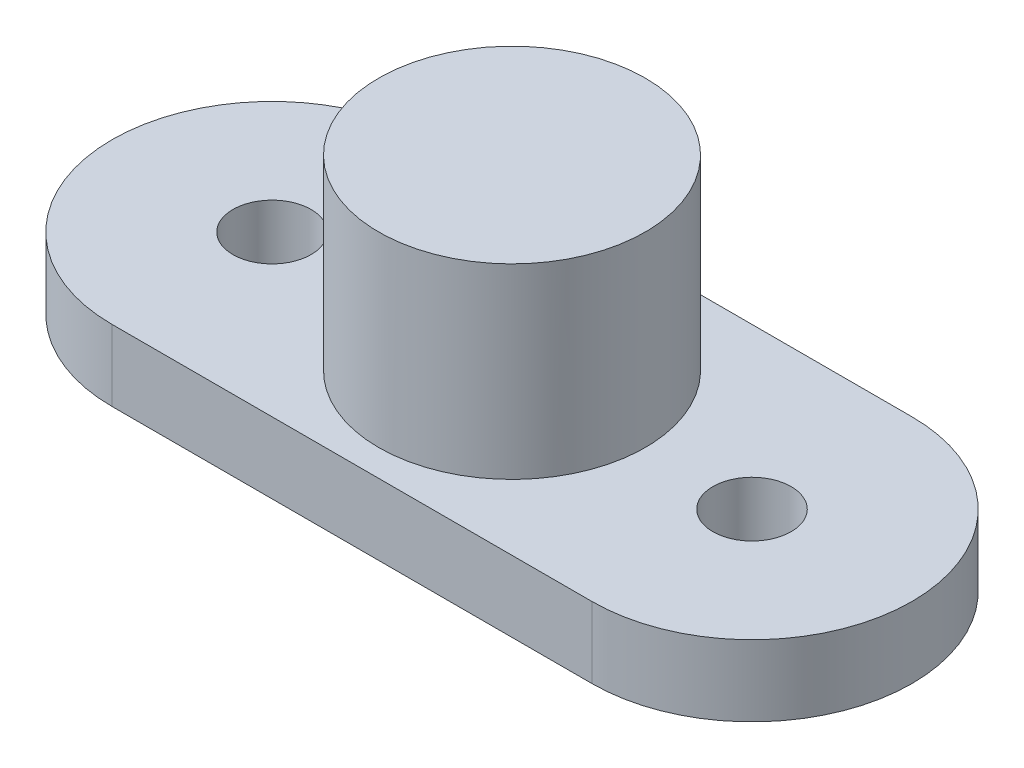
from build123d import *

# Parameters (mm, degrees)
SKETCH1_R           = 1.1
SKETCH1_R_2         = 3.75
BOSS_EXTRUDE3_DEPTH = 2
SKETCH3_R           = 3.75
BOSS_EXTRUDE4_DEPTH = 7.25


with BuildPart() as part:
    # Sketch1 → Boss-Extrude3 (new body)
    with BuildSketch(Plane(origin=(0, 0, 0), x_dir=(1, 0, 0), z_dir=(0, 1, 0))):
        with BuildLine():
            Line((-6.75, 4.499502967), (6.75, 4.499502967))
            ThreePointArc((6.75, 4.499502967), (11.249502967, 0), (6.75, -4.499502967))
            Line((6.75, -4.499502967), (-6.75, -4.499502967))
            ThreePointArc((-6.75, -4.499502967), (-11.249502967, 0), (-6.75, 4.499502967))
        make_face()
        with Locations((-6.75, 0)):
            Circle(SKETCH1_R, mode=Mode.SUBTRACT)
        with Locations((6.75, 0)):
            Circle(SKETCH1_R, mode=Mode.SUBTRACT)
        Circle(SKETCH1_R_2, mode=Mode.SUBTRACT)
    extrude(amount=BOSS_EXTRUDE3_DEPTH)

    # Sketch3 → Boss-Extrude4 (add)
    with BuildSketch(Plane.XZ):
        Circle(SKETCH3_R)
    extrude(amount=-BOSS_EXTRUDE4_DEPTH)


solid = part.part
